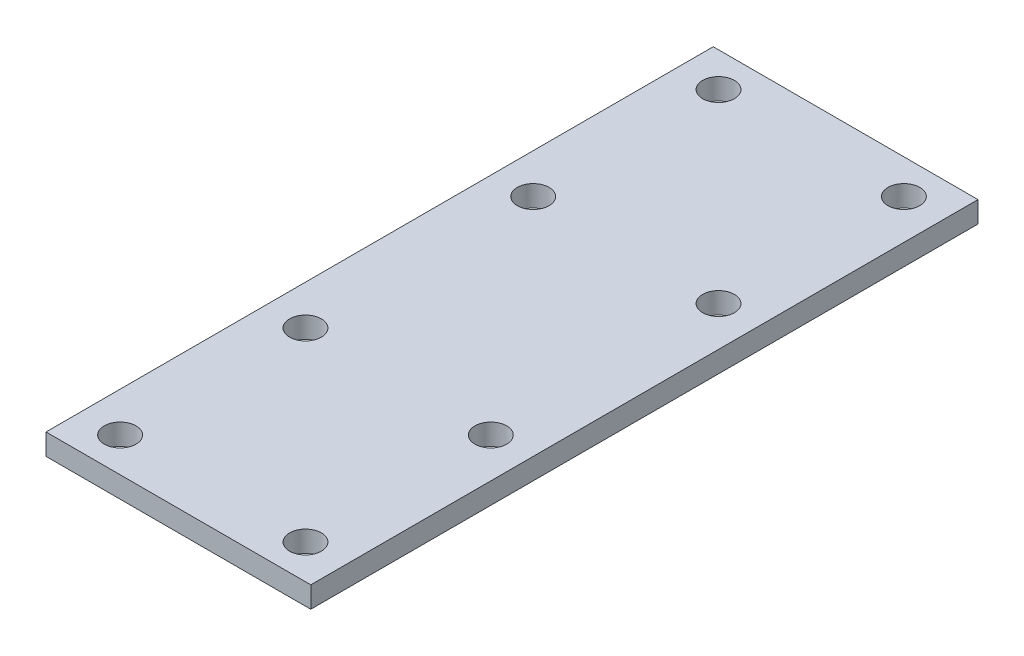
from build123d import *

# Parameters (mm, degrees)
SKETCH1_W           = 50
SKETCH1_H           = 126
SKETCH1_R           = 3
BOSS_EXTRUDE1_DEPTH = 4


with BuildPart() as part:
    # Sketch1 → Boss-Extrude1 (new body)
    with BuildSketch(Plane(origin=(0, 0, 0), x_dir=(1, 0, 0), z_dir=(0, 1, 0))):
        with Locations((25, 63)):
            Rectangle(SKETCH1_W, SKETCH1_H)
        with Locations((7.5, 119.5)):
            Circle(SKETCH1_R, mode=Mode.SUBTRACT)
        with Locations((7.5, 84.5)):
            Circle(SKETCH1_R, mode=Mode.SUBTRACT)
        with Locations((42.5, 84.5)):
            Circle(SKETCH1_R, mode=Mode.SUBTRACT)
        with Locations((42.5, 119.5)):
            Circle(SKETCH1_R, mode=Mode.SUBTRACT)
        with Locations((7.5, 41.5)):
            Circle(SKETCH1_R, mode=Mode.SUBTRACT)
        with Locations((7.5, 6.5)):
            Circle(SKETCH1_R, mode=Mode.SUBTRACT)
        with Locations((42.5, 6.5)):
            Circle(SKETCH1_R, mode=Mode.SUBTRACT)
        with Locations((42.5, 41.5)):
            Circle(SKETCH1_R, mode=Mode.SUBTRACT)
    extrude(amount=BOSS_EXTRUDE1_DEPTH)


solid = part.part
